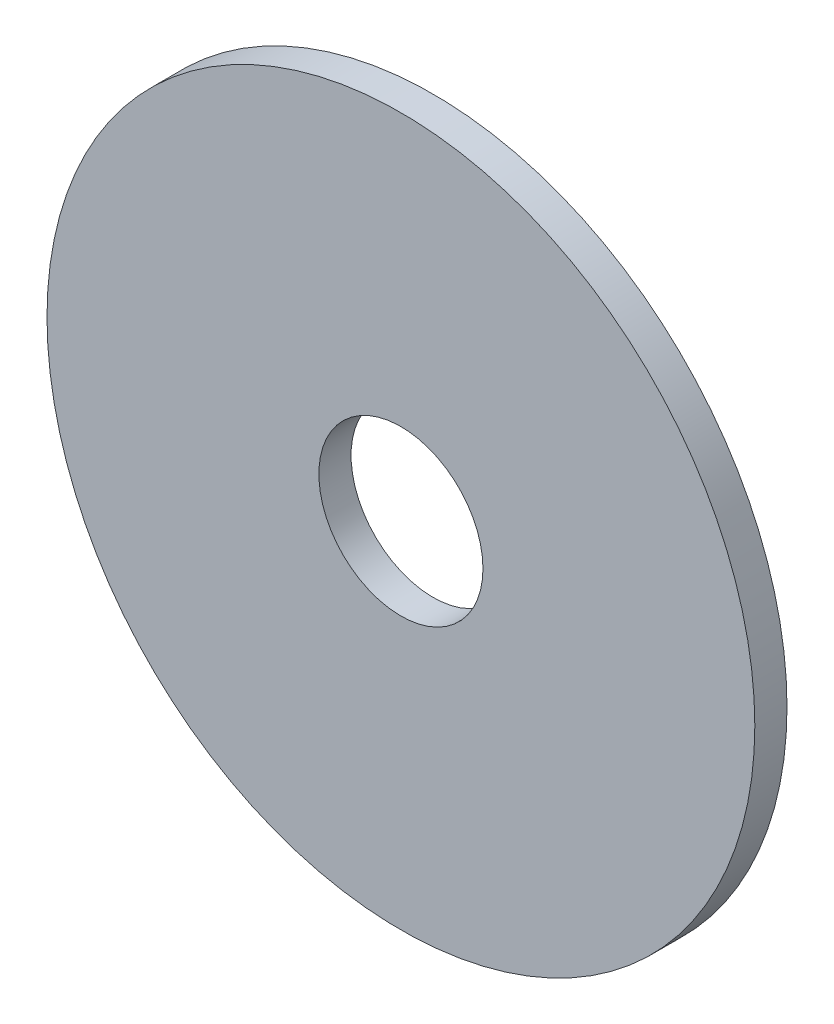
from build123d import *

# Parameters (mm, degrees)
ESQUISSE1_R        = 110
ESQUISSE1_R_2      = 25.5
BOSS_EXTRU_1_DEPTH = 10


with BuildPart() as part:
    # Esquisse1 → Boss.-Extru.1 (new body)
    with BuildSketch(Plane.XY):
        Circle(ESQUISSE1_R)
        Circle(ESQUISSE1_R_2, mode=Mode.SUBTRACT)
    extrude(amount=BOSS_EXTRU_1_DEPTH)


solid = part.part
